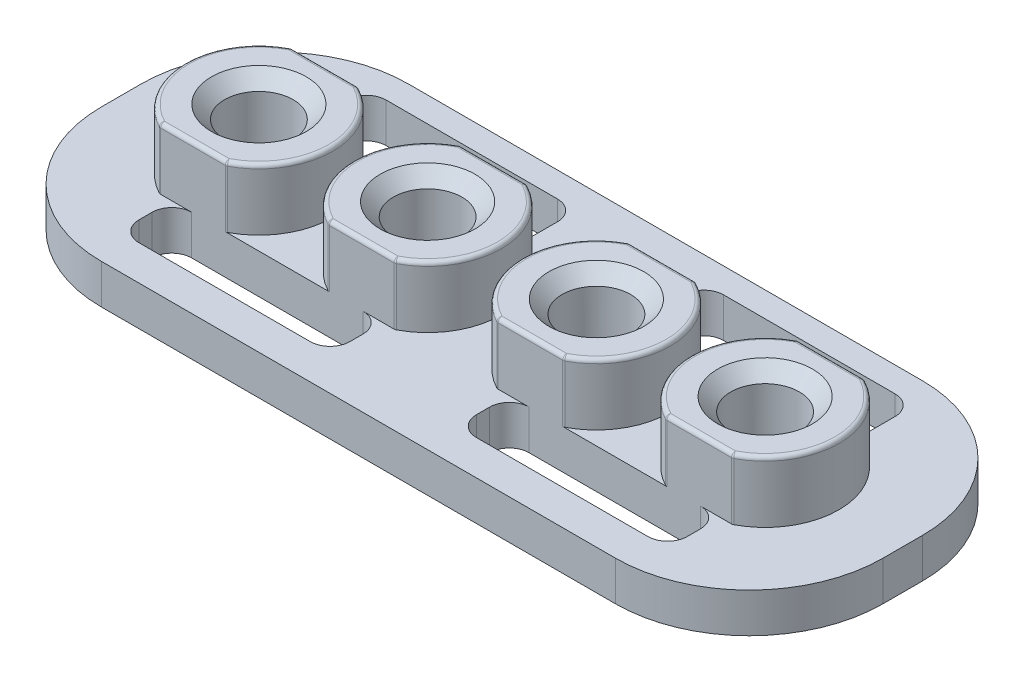
from build123d import *

# Parameters (mm, degrees)
SKETCH1_W           = 15.05966
SKETCH1_H           = 5.9182
BOSS_EXTRUDE1_DEPTH = 0.762
FILLET1_R           = 2.5781
SKETCH2_R           = 1.4224
BOSS_EXTRUDE2_DEPTH = 1.1811
SKETCH3_W           = 15.05966
SKETCH3_H           = 4.599336766
CUT_EXTRUDE1_DEPTH  = 1.1811
SKETCH4_R           = 0.6604
CUT_EXTRUDE2_DEPTH  = 1.397
SKETCH5_W           = 4.064
SKETCH5_H           = 1.2065
SKETCH5_H_2         = 1.016
CUT_EXTRUDE3_DEPTH  = 1.762
FILLET2_R           = 0.381
CHAMFER1_SIZE       = 0.254
FILLET3_R           = 0.127
FILLET4_R           = 0.0762


with BuildPart() as part:
    # Sketch1 → Boss-Extrude1 (new body)
    with BuildSketch(Plane(origin=(0, 0, 0), x_dir=(1, 0, 0), z_dir=(0, 1, 0))):
        Rectangle(SKETCH1_W, SKETCH1_H)
    extrude(amount=BOSS_EXTRUDE1_DEPTH)

    # Fillet1
    fillet1_edges = [part.edges().sort_by_distance(p)[0] for p in [
        (-7.52983, 0.381, -2.9591),
        (7.52983, 0.381, -2.9591),
        (7.52983, 0.381, 2.9591),
        (-7.52983, 0.381, 2.9591),
    ]]
    fillet(fillet1_edges, radius=FILLET1_R)

    # Sketch2 → Boss-Extrude2 (add)
    with BuildSketch(Plane(origin=(0, 0.762, 0), x_dir=(1, 0, 0), z_dir=(0, 1, 0))):
        with Locations((-4.8768, 0)):
            Circle(SKETCH2_R)
        with Locations((-1.6256, 0)):
            Circle(SKETCH2_R)
        with Locations((1.6256, 0)):
            Circle(SKETCH2_R)
        with Locations((4.8768, 0)):
            Circle(SKETCH2_R)
    extrude(amount=BOSS_EXTRUDE2_DEPTH)

    # Sketch3 → Cut-Extrude1 (cut)
    with BuildSketch(Plane(origin=(0, 1.9431, 0), x_dir=(1, 0, 0), z_dir=(0, 1, 0))):
        with Locations((0, 3.569668383)):
            Rectangle(SKETCH3_W, SKETCH3_H)
        with Locations((0, -3.569668383)):
            Rectangle(SKETCH3_W, SKETCH3_H)
    extrude(amount=-CUT_EXTRUDE1_DEPTH, mode=Mode.SUBTRACT)

    # Sketch4 → Cut-Extrude2 (cut)
    with BuildSketch(Plane(origin=(0, 1.9431, 0), x_dir=(1, 0, 0), z_dir=(0, 1, 0))):
        with Locations((-4.8768, 0)):
            Circle(SKETCH4_R)
        with Locations((-1.6256, 0)):
            Circle(SKETCH4_R)
        with Locations((1.6256, 0)):
            Circle(SKETCH4_R)
        with Locations((4.8768, 0)):
            Circle(SKETCH4_R)
    extrude(amount=-CUT_EXTRUDE2_DEPTH, mode=Mode.SUBTRACT)

    # Sketch5 → Cut-Extrude3 (cut, through all)
    with BuildSketch(Plane(origin=(0, 0.762, 0), x_dir=(1, 0, 0), z_dir=(0, 1, 0))):
        with Locations((-3.2512, 1.87325)):
            Rectangle(SKETCH5_W, SKETCH5_H)
        with Locations((-3.2512, -1.778)):
            Rectangle(SKETCH5_W, SKETCH5_H_2)
        with Locations((3.2512, -1.778)):
            Rectangle(SKETCH5_W, SKETCH5_H_2)
        with Locations((3.2512, 1.87325)):
            Rectangle(SKETCH5_W, SKETCH5_H)
    extrude(amount=-CUT_EXTRUDE3_DEPTH, mode=Mode.SUBTRACT)

    # Fillet2
    fillet2_edges = [part.edges().sort_by_distance(p)[0] for p in [
        (-5.2832, 0.381, -1.27),
        (-5.2832, 0.381, -2.4765),
        (-1.2192, 0.381, -2.4765),
        (-1.2192, 0.381, -1.27),
        (-5.2832, 0.381, 2.286),
        (-5.2832, 0.381, 1.27),
        (-1.2192, 0.381, 1.27),
        (-1.2192, 0.381, 2.286),
        (1.2192, 0.381, 1.27),
        (5.2832, 0.381, 1.27),
        (5.2832, 0.381, 2.286),
        (1.2192, 0.381, 2.286),
        (1.2192, 0.381, -2.4765),
        (5.2832, 0.381, -2.4765),
        (5.2832, 0.381, -1.27),
        (1.2192, 0.381, -1.27),
    ]]
    fillet(fillet2_edges, radius=FILLET2_R)

    # Chamfer1
    chamfer1_edges = [part.edges().sort_by_distance(p)[0] for p in [
        (-5.5372, 1.9431, 0),
        (-2.286, 1.9431, 0),
        (0.9652, 1.9431, 0),
        (4.2164, 1.9431, 0),
    ]]
    chamfer(chamfer1_edges, length=CHAMFER1_SIZE)

    # Fillet3
    fillet3_edges = [part.edges().sort_by_distance(p)[0] for p in [
        (-5.5372, 0.5461, 0),
        (-2.286, 0.5461, 0),
        (0.9652, 0.5461, 0),
        (4.2164, 0.5461, 0),
    ]]
    fillet(fillet3_edges, radius=FILLET3_R)

    # Fillet4
    fillet4_edges = [part.edges().sort_by_distance(p)[0] for p in [
        (-4.8768, 1.9431, 1.27),
        (-1.6256, 1.9431, 1.27),
        (1.6256, 1.9431, 1.27),
        (-4.236236373, 1.35255, 1.27),
        (-5.517363627, 1.35255, 1.27),
        (-0.985036373, 1.35255, 1.27),
        (-2.266163627, 1.35255, 1.27),
        (2.266163627, 1.35255, 1.27),
        (0.985036373, 1.35255, 1.27),
        (5.517363627, 1.35255, 1.27),
        (4.236236373, 1.35255, 1.27),
        (0.2032, 1.9431, 0),
        (3.4544, 1.9431, 0),
        (4.8768, 1.9431, -1.27),
        (-3.048, 1.9431, 0),
        (-6.2992, 1.9431, 0),
        (-4.8768, 1.9431, -1.27),
        (-1.6256, 1.9431, -1.27),
        (1.6256, 1.9431, -1.27),
        (-5.517363627, 1.35255, -1.27),
        (-4.236236373, 1.35255, -1.27),
        (-2.266163627, 1.35255, -1.27),
        (-0.985036373, 1.35255, -1.27),
        (0.985036373, 1.35255, -1.27),
        (2.266163627, 1.35255, -1.27),
        (4.236236373, 1.35255, -1.27),
        (5.517363627, 1.35255, -1.27),
        (6.2992, 1.9431, 0),
        (4.8768, 1.9431, 1.27),
        (3.048, 1.9431, 0),
        (-0.2032, 1.9431, 0),
        (-3.4544, 1.9431, 0),
    ]]
    fillet(fillet4_edges, radius=FILLET4_R)


solid = part.part
